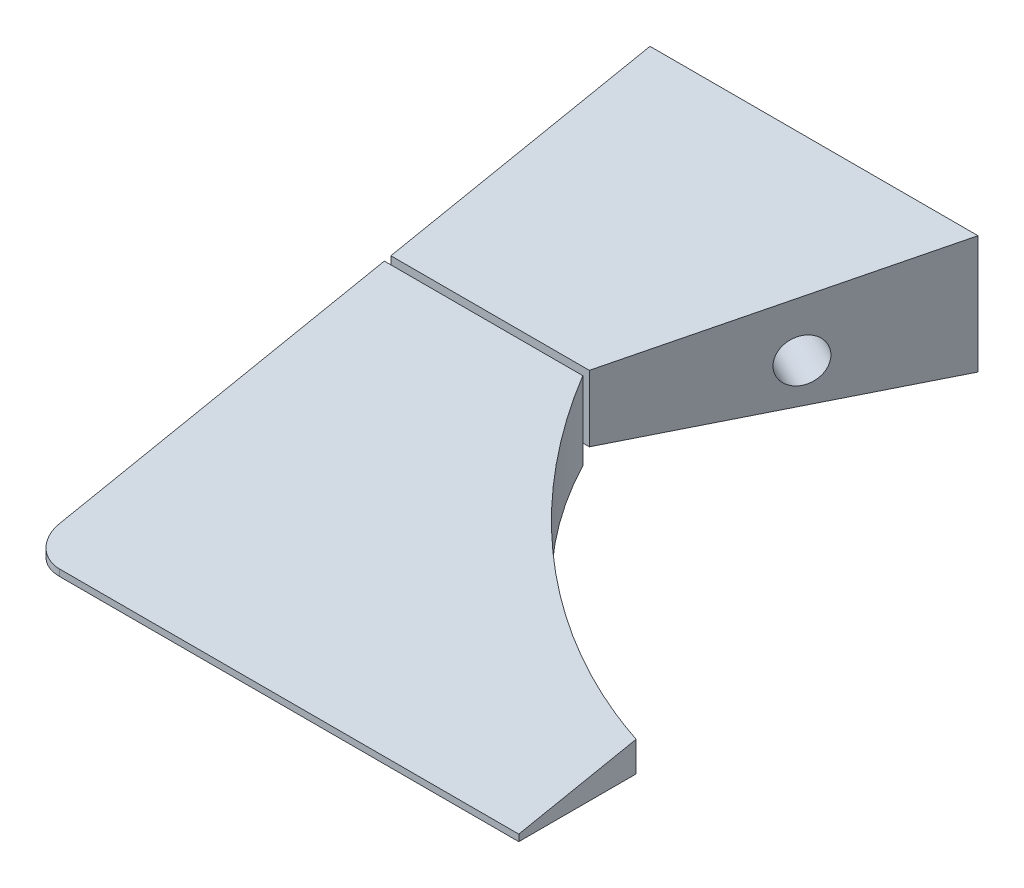
from build123d import *

# Parameters (mm, degrees)
ESBO_O1_W                                      = 130
ESBO_O1_H                                      = 20
RESSALTO_EXTRUS_O1_DEPTH                       = 95
CORTE_EXTRUS_O2_REACH                          = 22
CORTE_EXTRUS_O4_DEPTH                          = 1
CORTE_EXTRUS_O4_DEPTH_BACK                     = 131
BROCA_DE_ROSQUEAR_DE_CANO_PARA_TARRAXA_D_D     = 6.579997
BROCA_DE_ROSQUEAR_DE_CANO_PARA_TARRAXA_D_DEPTH = 10
BROCA_DE_ROSQUEAR_DE_CANO_PARA_TARRAXA_D_TIP   = 1.976830535
BROCA_DE_ROSQUEAR_DE_CANO_PARA_TARRA_2_D       = 6.579997
BROCA_DE_ROSQUEAR_DE_CANO_PARA_TARRA_2_DEPTH   = 10
BROCA_DE_ROSQUEAR_DE_CANO_PARA_TARRA_2_TIP     = 1.976830535
FILETE2_R                                      = 5
CORTE_EXTRUS_O7_DEPTH                          = 131
RESSALTO_EXTRUS_O2_REACH                       = 57.5
ESBO_O37_W                                     = 28.258303284
ESBO_O37_H                                     = 7.9
CORTE_EXTRUS_O8_REACH                          = 21.612
ESBO_O38_W                                     = 55
ESBO_O38_H                                     = 21.847631836
ESBO_O39_W                                     = 50
ESBO_O39_H                                     = 2
CORTE_EXTRUS_O9_DEPTH                          = 40.5


with BuildPart() as part:
    # Esboço1 → Ressalto-extrusão1 (new body)
    with BuildSketch(Plane.XY):
        Rectangle(ESBO_O1_W, ESBO_O1_H)
    extrude(amount=RESSALTO_EXTRUS_O1_DEPTH)

    # Esboço2 → Corte-extrusão2 (cut, up to next)
    with BuildSketch(Plane(origin=(0, 10, 0), x_dir=(1, 0, 0), z_dir=(0, 1, 0)), mode=Mode.PRIVATE) as corte_extrus_o2_sk1:
        with BuildLine():
            Line((65, 0), (-15, 0))
            Line((-15, 0), (-35, -40))
            ThreePointArc((-35, -40), (-7.92883262, -69.207295879), (30.404335441, -80))
            Line((30.404335441, -80), (65, -80))
            Line((65, -80), (65, 0))
        make_face()
    corte_extrus_o2_tool1 = extrude(corte_extrus_o2_sk1.sketch, amount=-CORTE_EXTRUS_O2_REACH, mode=Mode.PRIVATE) & part.part
    add(corte_extrus_o2_tool1.solids().sort_by_distance((21.312978, 10, 38.404428))[0], mode=Mode.SUBTRACT)

    # Esboço13 → Corte-extrusão4 (cut, two sides)
    with BuildSketch(Plane.ZY.offset(65)) as corte_extrus_o4_sk:
        Polygon((-200.200134404, 50.040026881), (0, 10), (95, -9), (295.200134404, -49.040026881), (375.280188165, 351.360241926), (-120.120080642, 450.440295688), align=None)
    extrude(amount=CORTE_EXTRUS_O4_DEPTH, mode=Mode.SUBTRACT)
    extrude(corte_extrus_o4_sk.sketch, amount=-CORTE_EXTRUS_O4_DEPTH_BACK, mode=Mode.SUBTRACT)

    # Broca de rosquear de cano para tarraxa d
    with Locations(Plane.ZY.offset(65)):
        with Locations((20, -2)):
            Hole(BROCA_DE_ROSQUEAR_DE_CANO_PARA_TARRAXA_D_D / 2, depth=BROCA_DE_ROSQUEAR_DE_CANO_PARA_TARRAXA_D_DEPTH)
            with Locations((0, 0, -(BROCA_DE_ROSQUEAR_DE_CANO_PARA_TARRAXA_D_DEPTH + BROCA_DE_ROSQUEAR_DE_CANO_PARA_TARRAXA_D_TIP / 2))):  # 118° drill point
                Cone(0, BROCA_DE_ROSQUEAR_DE_CANO_PARA_TARRAXA_D_D / 2, BROCA_DE_ROSQUEAR_DE_CANO_PARA_TARRAXA_D_TIP, mode=Mode.SUBTRACT)

    # Broca de rosquear de cano para tarra 2
    with Locations(Plane(origin=(-12, 0, -6), x_dir=(0.447213595, 0, -0.894427191), z_dir=(0.894427191, 0, 0.447213595))):
        with Locations((-26.708203932, -2)):
            Hole(BROCA_DE_ROSQUEAR_DE_CANO_PARA_TARRA_2_D / 2, depth=BROCA_DE_ROSQUEAR_DE_CANO_PARA_TARRA_2_DEPTH)
            with Locations((0, 0, -(BROCA_DE_ROSQUEAR_DE_CANO_PARA_TARRA_2_DEPTH + BROCA_DE_ROSQUEAR_DE_CANO_PARA_TARRA_2_TIP / 2))):  # 118° drill point
                Cone(0, BROCA_DE_ROSQUEAR_DE_CANO_PARA_TARRA_2_D / 2, BROCA_DE_ROSQUEAR_DE_CANO_PARA_TARRA_2_TIP, mode=Mode.SUBTRACT)

    # Filete2
    filete2_edges = [part.edges().sort_by_distance(p)[0] for p in [
        (-65, -9.5, 95),
    ]]
    fillet(filete2_edges, radius=FILETE2_R)

    # Esboço34 → Corte-extrusão7 (cut, through all)
    with BuildSketch(Plane.ZY.offset(65)):
        Polygon((40, -10), (40, 2), (39.5, 2.1), (39.5, -10), align=None)
        Polygon((40.5, 1.9), (40, 2), (40, -10), (40.5, -10), align=None)
    extrude(amount=-CORTE_EXTRUS_O7_DEPTH, mode=Mode.SUBTRACT)

    # Esboço37 → Ressalto-extrusão2 (add, up to next)
    with BuildSketch(Plane.XY.offset(39.5), mode=Mode.PRIVATE) as ressalto_extrus_o2_sk1:
        with Locations((-49.870848358, -3.05)):
            Rectangle(ESBO_O37_W, ESBO_O37_H)
    ressalto_extrus_o2_tool1 = extrude(ressalto_extrus_o2_sk1.sketch, amount=RESSALTO_EXTRUS_O2_REACH, mode=Mode.PRIVATE) - part.part
    add(ressalto_extrus_o2_tool1.solids().sort_by_distance((-49.870848, -3.05, 39.5))[0])

    # Esboço38 → Corte-extrusão8 (cut, up to next)
    with BuildSketch(Plane(origin=(0, 9.615384615, 1.923076923), x_dir=(1, 0, 0), z_dir=(0, 0.980580676, 0.196116135)), mode=Mode.PRIVATE) as corte_extrus_o8_sk1:
        with Locations((37.5, -84.932685446)):
            Rectangle(ESBO_O38_W, ESBO_O38_H)
    corte_extrus_o8_tool1 = extrude(corte_extrus_o8_sk1.sketch, amount=-CORTE_EXTRUS_O8_REACH, mode=Mode.PRIVATE) & part.part
    add(corte_extrus_o8_tool1.solids().sort_by_distance((37.5, -7.041285, 85.206427))[0], mode=Mode.SUBTRACT)

    # Esboço39 → Corte-extrusão9 (cut)
    with BuildSketch(Plane(origin=(0, 0, 0), x_dir=(-1, 0, 0), z_dir=(0, 0, -1))):
        with Locations((40, -9)):
            Rectangle(ESBO_O39_W, ESBO_O39_H)
    extrude(amount=-CORTE_EXTRUS_O9_DEPTH, mode=Mode.SUBTRACT)


solid = part.part
